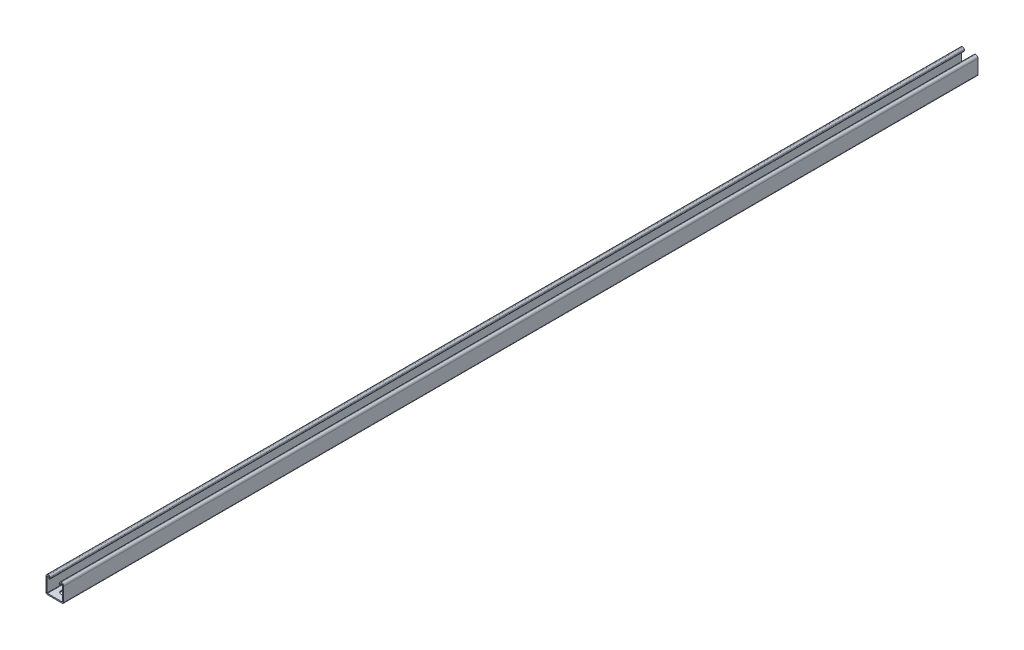
from build123d import *

# Parameters (mm, degrees)
PRIMARY_EXTRUSION_DEPTH = 2133.6
SLOT_CUT_DEPTH          = 2.667035
LPATTERN1_COUNT         = 42
LPATTERN1_PITCH         = 50.8


with BuildPart() as part:
    # Sketch1 → Primary Extrusion (new body)
    with BuildSketch(Plane.XY):
        with BuildLine():
            Line((17.176891111, -17.970376528), (-17.176891111, -17.970376528))
            ThreePointArc((-17.176891111, -17.970376528), (-17.738157147, -17.737892523), (-17.970641152, -17.176626487))
            Line((-17.970641152, -17.176626487), (-17.970641152, 15.589126408))
            ThreePointArc((-17.970641152, 15.589126408), (-17.273189139, 17.272924515), (-15.589391032, 17.970376528))
            Line((-15.589391032, 17.970376528), (-14.57342631, 17.970376528))
            ThreePointArc((-14.57342631, 17.970376528), (-14.012171972, 17.737897369), (-13.779692813, 17.176643031))
            Line((-13.779692813, 17.176643031), (-13.779692813, 14.833457753))
            ThreePointArc((-13.779692813, 14.833457753), (-12.446175174, 13.499940114), (-11.112657535, 14.833457753))
            Line((-11.112657535, 14.833457753), (-11.112657535, 17.176643031))
            ThreePointArc((-11.112657535, 17.176643031), (-12.126293241, 19.623776099), (-14.57342631, 20.637411806))
            Line((-14.57342631, 20.637411806), (-15.589391032, 20.637411806))
            ThreePointArc((-15.589391032, 20.637411806), (-19.15906787, 19.158803246), (-20.637676429, 15.589126408))
            Line((-20.637676429, 15.589126408), (-20.637676429, -17.176626487))
            ThreePointArc((-20.637676429, -17.176626487), (-19.624035878, -19.623771254), (-17.176891111, -20.637411806))
            Line((-17.176891111, -20.637411806), (17.176891111, -20.637411806))
            ThreePointArc((17.176891111, -20.637411806), (19.624035878, -19.623771254), (20.637676429, -17.176626487))
            Line((20.637676429, -17.176626487), (20.637676429, 15.589126408))
            ThreePointArc((20.637676429, 15.589126408), (19.15906787, 19.158803246), (15.589391032, 20.637411806))
            Line((15.589391032, 20.637411806), (14.57342631, 20.637411806))
            ThreePointArc((14.57342631, 20.637411806), (12.126293241, 19.623776099), (11.112657535, 17.176643031))
            Line((11.112657535, 17.176643031), (11.112657535, 14.833457753))
            ThreePointArc((11.112657535, 14.833457753), (12.446175174, 13.499940114), (13.779692813, 14.833457753))
            Line((13.779692813, 14.833457753), (13.779692813, 17.176643031))
            ThreePointArc((13.779692813, 17.176643031), (14.012171972, 17.737897369), (14.57342631, 17.970376528))
            Line((14.57342631, 17.970376528), (15.589391032, 17.970376528))
            ThreePointArc((15.589391032, 17.970376528), (17.273189139, 17.272924515), (17.970641152, 15.589126408))
            Line((17.970641152, 15.589126408), (17.970641152, -17.176626487))
            ThreePointArc((17.970641152, -17.176626487), (17.738157147, -17.737892523), (17.176891111, -17.970376528))
        make_face()
    extrude(amount=-PRIMARY_EXTRUSION_DEPTH)

    # Sketch58 → Slot Cut (cut)
    with BuildSketch(Plane(origin=(0, -20.637411806, 0), x_dir=(-1, 0, 0), z_dir=(0, 1, 0))):
        with BuildLine():
            Line((7.14375, -29.36875), (7.14375, -21.43125))
            ThreePointArc((7.14375, -21.43125), (0, -14.2875), (-7.14375, -21.43125))
            Line((-7.14375, -21.43125), (-7.14375, -29.36875))
            ThreePointArc((-7.14375, -29.36875), (0, -36.5125), (7.14375, -29.36875))
        make_face()
    slot_cut = extrude(amount=SLOT_CUT_DEPTH, mode=Mode.SUBTRACT)

    # LPattern1: Slot Cut ×42
    with Locations(*[(0, 0, -i * LPATTERN1_PITCH) for i in range(1, LPATTERN1_COUNT)]):
        add(slot_cut, mode=Mode.SUBTRACT)


solid = part.part
